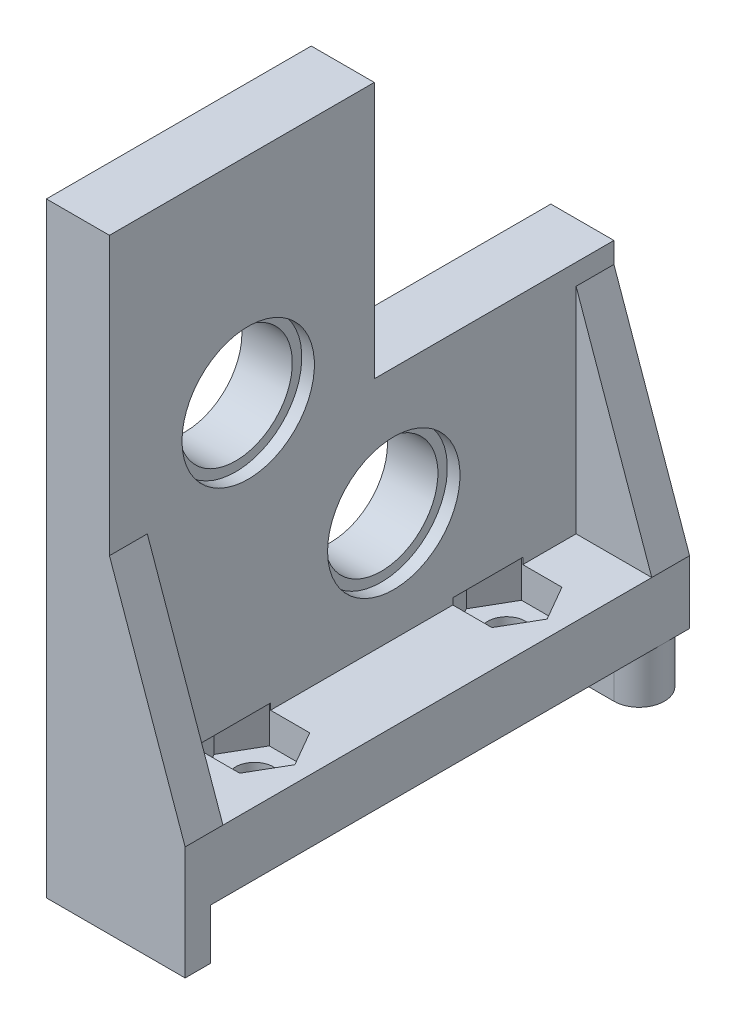
from build123d import *

# Parameters (mm, degrees)
SKETCH_1_W               = 40
SKETCH_1_H               = 44
SKETCH_1_R               = 4.5
EXTRUDE_1_DEPTH          = 5
SKETCH_2_R               = 5.25
CUT_EXTRUDE_1_DEPTH      = 1
CUT_EXTRUDE_2_REACH      = 7
SKETCH_3_W               = 19
SKETCH_3_H               = 20.351449313
SKETCH_4_W               = 40
SKETCH_4_H               = 5
EXTRUDE_2_DEPTH          = 6
EXTRUDE_3_DEPTH          = 4
SKETCH_6_R               = 1.5
CUT_EXTRUDE_4_DEPTH      = 5
CUT_EXTRUDE_5_DEPTH      = 0.5
CUT_EXTRUDE_5_DEPTH_BACK = 2.5
EXTRUDE_4_DEPTH          = 3
EXTRUDE_5_DEPTH          = 3


with BuildPart() as part:
    # 草图1 → 凸台-拉伸1 (new body)
    with BuildSketch(Plane(origin=(0, 0, 0), x_dir=(0, 0, -1), z_dir=(1, 0, 0))):
        with Locations((9, -5)):
            Rectangle(SKETCH_1_W, SKETCH_1_H)
        Circle(SKETCH_1_R, mode=Mode.SUBTRACT)
        with Locations((18, 6)):
            Circle(SKETCH_1_R, mode=Mode.SUBTRACT)
        with Locations((11.543885882, -13.351449313)):
            Circle(SKETCH_1_R, mode=Mode.SUBTRACT)
    extrude(amount=EXTRUDE_1_DEPTH)

    # 草图2 → 切除-拉伸1 (cut)
    with BuildSketch(Plane.ZY.offset(-5)):
        with Locations((-18, 6)):
            Circle(SKETCH_2_R)
        Circle(SKETCH_2_R)
        with Locations((-11.543885882, -13.351449313)):
            Circle(SKETCH_2_R)
    extrude(amount=CUT_EXTRUDE_1_DEPTH, mode=Mode.SUBTRACT)

    # 草图3 → 切除-拉伸2 (cut, up to next)
    with BuildSketch(Plane(origin=(5, 0, 0), x_dir=(0, 0, -1), z_dir=(1, 0, 0)), mode=Mode.PRIVATE) as cut_extrude_2_sk1:
        with Locations((19.5, 6.824275344)):
            Rectangle(SKETCH_3_W, SKETCH_3_H)
    cut_extrude_2_tool1 = extrude(cut_extrude_2_sk1.sketch, amount=-CUT_EXTRUDE_2_REACH, mode=Mode.PRIVATE) & part.part
    add(cut_extrude_2_tool1.solids().sort_by_distance((5, 6.824275, -19.5))[0], mode=Mode.SUBTRACT)

    # 草图4 → 凸台-拉伸2 (add)
    with BuildSketch(Plane(origin=(5, 0, 0), x_dir=(0, 0, -1), z_dir=(1, 0, 0))):
        with Locations((9, -24.5)):
            Rectangle(SKETCH_4_W, SKETCH_4_H)
    extrude(amount=EXTRUDE_2_DEPTH)

    # 草图5 → 凸台-拉伸3 (add)
    with BuildSketch(Plane.XZ.offset(27)):
        Polygon((0, 11), (11, 11), (11, 9), (8.8, 9), (5.5, 6), (2.2, 9), (0, 9), align=None)
        with BuildLine():
            Line((0, -29), (9, -29))
            ThreePointArc((9, -29), (11, -27), (9, -25))
            Line((9, -25), (0, -25))
            Line((0, -25), (0, -29))
        make_face()
    extrude(amount=EXTRUDE_3_DEPTH)

    # 草图6 → 切除-拉伸4 (cut)
    with BuildSketch(Plane.XZ.offset(27)):
        with Locations((6.5, -19)):
            Circle(SKETCH_6_R)
        with Locations((6.5, 1)):
            Circle(SKETCH_6_R)
    extrude(amount=-CUT_EXTRUDE_4_DEPTH, mode=Mode.SUBTRACT)

    # 草图7 → 切除-拉伸5 (cut, two sides)
    with BuildSketch(Plane(origin=(0, -22, 0), x_dir=(-1, 0, 0), z_dir=(0, 1, 0))) as cut_extrude_5_sk:
        Polygon((-9.704293994, -19), (-8.102146997, -21.775), (-4.897853003, -21.775), (-3.295706006, -19), (-4.897853003, -16.225), (-8.102146997, -16.225), align=None)
        Polygon((-9.704293994, 1), (-8.102146997, -1.775), (-4.897853003, -1.775), (-3.295706006, 1), (-4.897853003, 3.775), (-8.102146997, 3.775), align=None)
    extrude(amount=CUT_EXTRUDE_5_DEPTH, mode=Mode.SUBTRACT)
    extrude(cut_extrude_5_sk.sketch, amount=-CUT_EXTRUDE_5_DEPTH_BACK, mode=Mode.SUBTRACT)

    # 草图8 → 凸台-拉伸4 (add)
    with BuildSketch(Plane.XY.offset(11)):
        Polygon((5, -22), (11, -22), (5, -5), align=None)
    extrude(amount=-EXTRUDE_4_DEPTH)

    # 草图9 → 凸台-拉伸5 (add)
    with BuildSketch(Plane(origin=(0, 0, -29), x_dir=(-1, 0, 0), z_dir=(0, 0, -1))):
        Polygon((-5, -22), (-11, -22), (-5, -5), align=None)
    extrude(amount=-EXTRUDE_5_DEPTH)


solid = part.part
